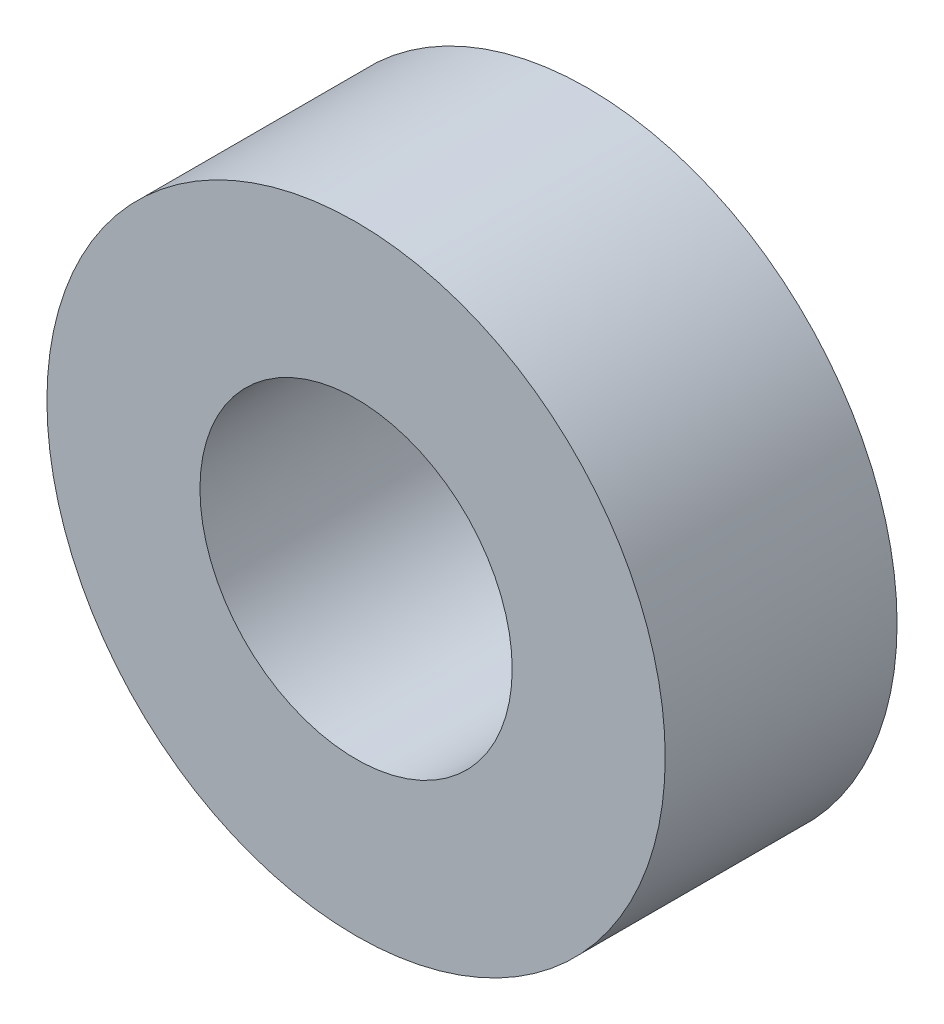
from build123d import *

# Parameters (mm, degrees)
SKETCH1_R           = 12.7
SKETCH1_R_2         = 6.4135
BOSS_EXTRUDE1_DEPTH = 9.525


with BuildPart() as part:
    # Sketch1 → Boss-Extrude1 (new body)
    with BuildSketch(Plane.XY):
        Circle(SKETCH1_R)
        Circle(SKETCH1_R_2, mode=Mode.SUBTRACT)
    extrude(amount=BOSS_EXTRUDE1_DEPTH)


solid = part.part
